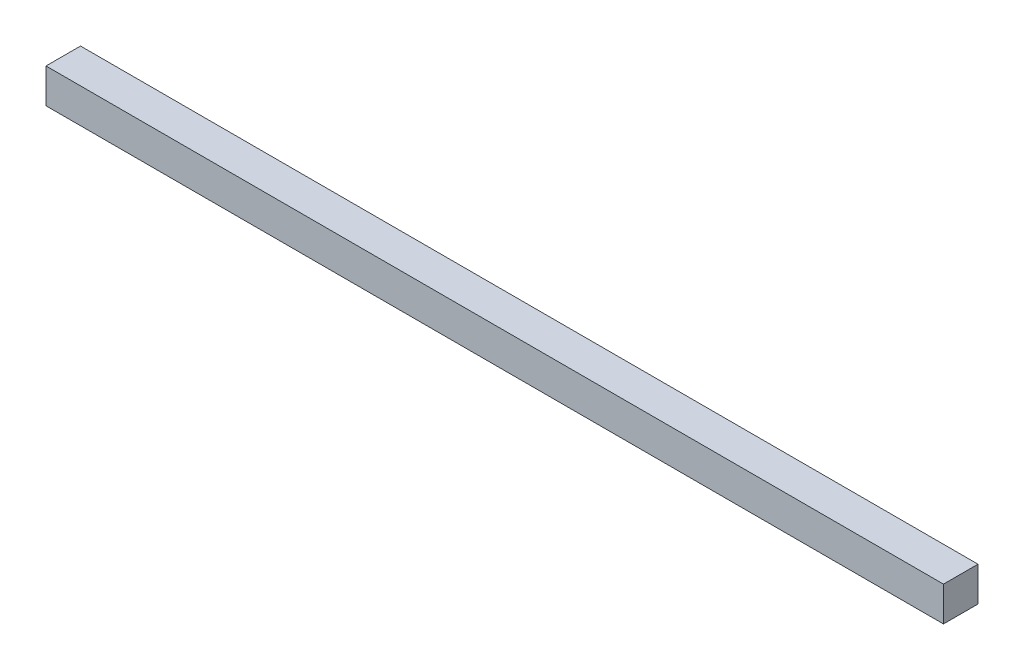
from build123d import *

# Parameters (mm, degrees)
SKETCH1_W           = 260
SKETCH1_H           = 10
BOSS_EXTRUDE1_DEPTH = 10


with BuildPart() as part:
    # Sketch1 → Boss-Extrude1 (new body)
    with BuildSketch(Plane(origin=(0, 0, 0), x_dir=(1, 0, 0), z_dir=(0, 1, 0))):
        Rectangle(SKETCH1_W, SKETCH1_H)
    extrude(amount=BOSS_EXTRUDE1_DEPTH)


solid = part.part
